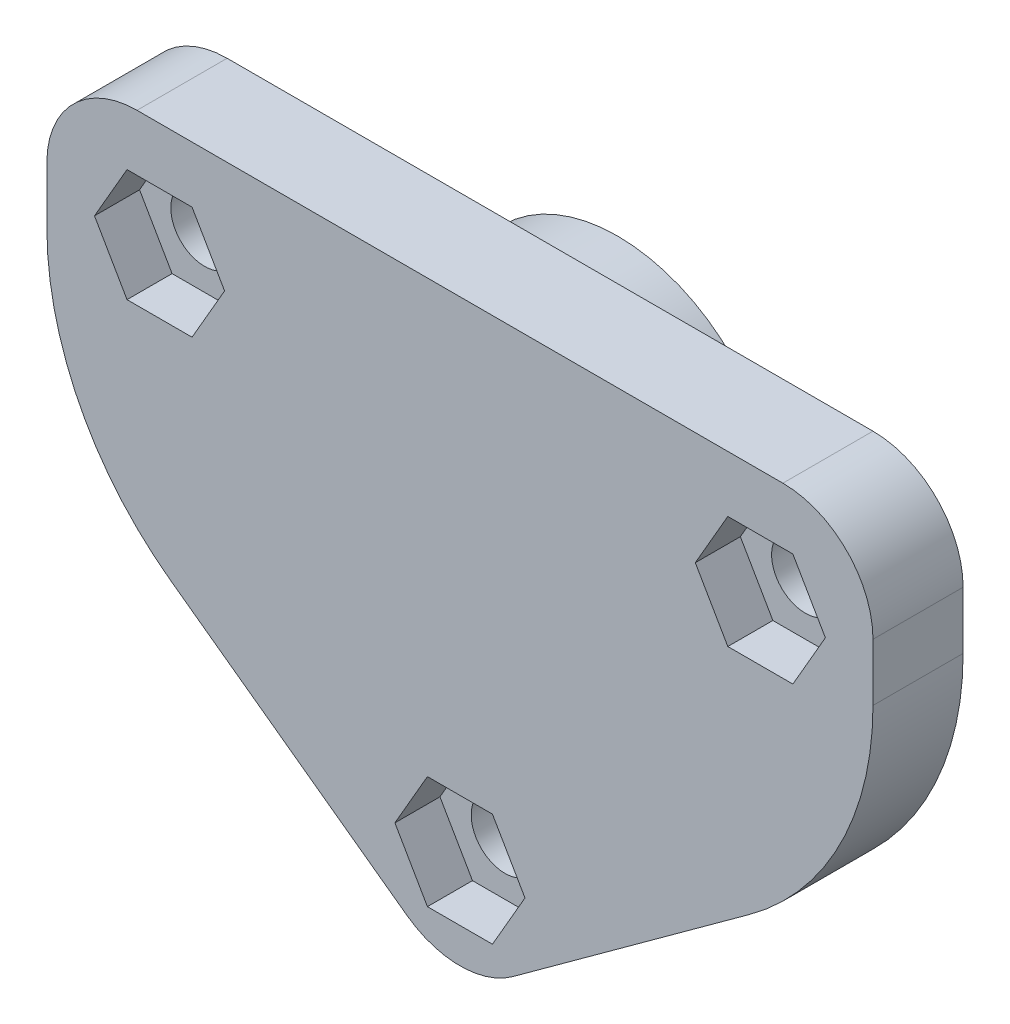
from build123d import *

# Parameters (mm, degrees)
ESQUISSE1_R             = 2.25
BOSS_EXTRU_1_DEPTH      = 6
CONG_2_R                = 6
CONG_3_R                = 20
ESQUISSE2_R             = 10.75
BOSS_EXTRU_2_DEPTH      = 4.5
ENL_V_MAT_EXTRU_1_DEPTH = 3


with BuildPart() as part:
    # Esquisse1 → Boss.-Extru.1 (new body)
    with BuildSketch(Plane.XY):
        Polygon((-55, 20), (-27.5, 0), (0, 20), (0, 40), (-55, 40), align=None)
        with Locations((-47.5, 32.5)):
            Circle(ESQUISSE1_R, mode=Mode.SUBTRACT)
        with Locations((-7.5, 32.5)):
            Circle(ESQUISSE1_R, mode=Mode.SUBTRACT)
        with Locations((-27.5, 7.5)):
            Circle(ESQUISSE1_R, mode=Mode.SUBTRACT)
    extrude(amount=BOSS_EXTRU_1_DEPTH)

    # Congé2
    cong_2_edges = [part.edges().sort_by_distance(p)[0] for p in [
        (-55, 40, 3),
        (0, 40, 3),
        (-27.5, 0, 3),
    ]]
    fillet(cong_2_edges, radius=CONG_2_R)

    # Congé3
    cong_3_edges = [part.edges().sort_by_distance(p)[0] for p in [
        (0, 20, 3),
        (-55, 20, 3),
    ]]
    fillet(cong_3_edges, radius=CONG_3_R)

    # Esquisse2 → Boss.-Extru.2 (add)
    with BuildSketch(Plane(origin=(0, 0, 0), x_dir=(-1, 0, 0), z_dir=(0, 0, -1))):
        with Locations(Location((27.5, 27.5, 0), (0, 0, 180))):  # turned: the seam where the file's is
            Circle(ESQUISSE2_R)
    extrude(amount=BOSS_EXTRU_2_DEPTH)

    # Esquisse3 → Enlèvement de matière-Révolution5 (revolve, cut)
    with BuildSketch(Plane(origin=(0, 0, -4.5), x_dir=(-1, 0, 0), z_dir=(0, 0, -1))):
        with BuildLine():
            Line((27.5, 30.25), (27.5, 24.75))
            ThreePointArc((27.5, 24.75), (24.75, 27.5), (27.5, 30.25))
        make_face()
    revolve(axis=Axis((-27.5, 30.25, -4.5), (0, -1, 0)), mode=Mode.SUBTRACT)

    # Esquisse4 → Enlèv. mat.-Extru.1 (cut)
    with BuildSketch(Plane.XY.offset(6)):
        Polygon((-43.169872981, 32.5), (-45.334936491, 36.25), (-49.665063509, 36.25), (-51.830127019, 32.5), (-49.665063509, 28.75), (-45.334936491, 28.75), align=None)
        Polygon((-11.830127019, 32.5), (-9.665063509, 28.75), (-5.334936491, 28.75), (-3.169872981, 32.5), (-5.334936491, 36.25), (-9.665063509, 36.25), align=None)
        Polygon((-23.169872981, 7.5), (-25.334936491, 11.25), (-29.665063509, 11.25), (-31.830127019, 7.5), (-29.665063509, 3.75), (-25.334936491, 3.75), align=None)
    extrude(amount=-ENL_V_MAT_EXTRU_1_DEPTH, mode=Mode.SUBTRACT)


solid = part.part
